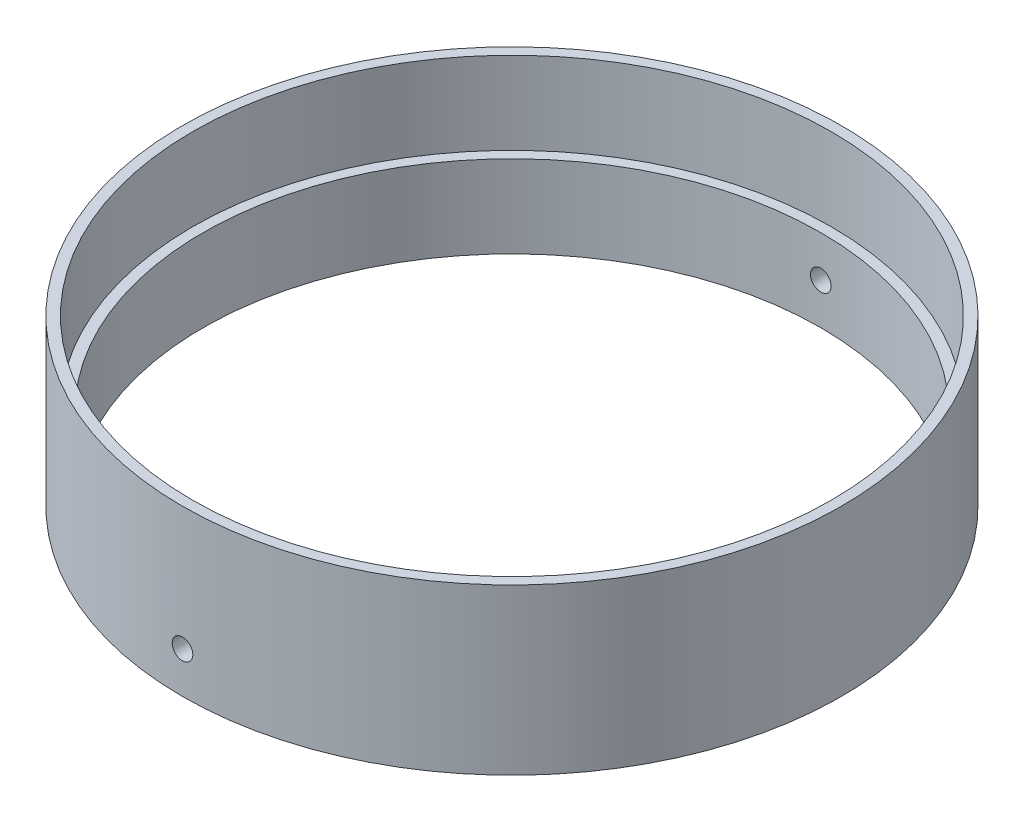
from build123d import *

# Parameters (mm, degrees)
SKETCH1_R               = 101.6
SKETCH1_R_2             = 95.25
BOSS_EXTRUDE1_DEPTH     = 25.4
SKETCH2_R               = 3.175
CUT_EXTRUDE1_DEPTH      = 102.6
CUT_EXTRUDE1_DEPTH_BACK = 102.6
SKETCH5_R               = 101.6
SKETCH5_R_2             = 98.425
BOSS_EXTRUDE2_DEPTH     = 146.05
SKETCH9_R               = 2.1
CUT_EXTRUDE5_DEPTH      = 204.2000001
SKETCH10_R              = 101.6
CUT_EXTRUDE6_DEPTH      = 120.65


with BuildPart() as part:
    # Sketch1 → Boss-Extrude1 (new body)
    with BuildSketch(Plane(origin=(0, 0, 0), x_dir=(1, 0, 0), z_dir=(0, 1, 0))):
        Circle(SKETCH1_R)
        Circle(SKETCH1_R_2, mode=Mode.SUBTRACT)
    extrude(amount=BOSS_EXTRUDE1_DEPTH)

    # Sketch2 → Cut-Extrude1 (cut, two sides)
    with BuildSketch(Plane.XY) as cut_extrude1_sk:
        with Locations((0, 12.7)):
            Circle(SKETCH2_R)
    extrude(amount=CUT_EXTRUDE1_DEPTH, mode=Mode.SUBTRACT)
    extrude(cut_extrude1_sk.sketch, amount=-CUT_EXTRUDE1_DEPTH_BACK, mode=Mode.SUBTRACT)

    # Sketch5 → Boss-Extrude2 (add)
    with BuildSketch(Plane(origin=(0, 25.4, 0), x_dir=(1, 0, 0), z_dir=(0, 1, 0))):
        Circle(SKETCH5_R)
        Circle(SKETCH5_R_2, mode=Mode.SUBTRACT)
    extrude(amount=BOSS_EXTRUDE2_DEPTH)

    # Sketch9 → Cut-Extrude5 (cut, through all)
    with BuildSketch(Plane.XY.offset(101.6)):
        with Locations((-85.075, 156.8)):
            Circle(SKETCH9_R)
    extrude(amount=-CUT_EXTRUDE5_DEPTH, mode=Mode.SUBTRACT)

    # Sketch10 → Cut-Extrude6 (cut)
    with BuildSketch(Plane(origin=(0, 171.45, 0), x_dir=(1, 0, 0), z_dir=(0, 1, 0))):
        Circle(SKETCH10_R)
    extrude(amount=-CUT_EXTRUDE6_DEPTH, mode=Mode.SUBTRACT)


solid = part.part
